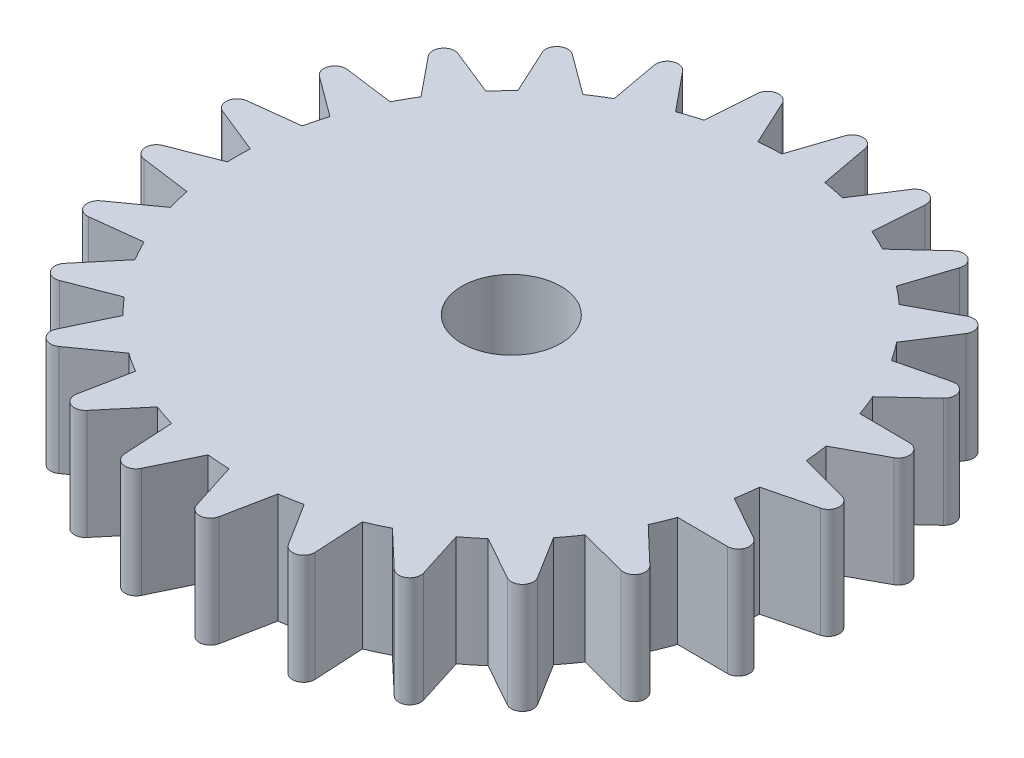
from build123d import *

# Parameters (mm, degrees)
BOSS_EXTRUDE1_DEPTH = 5
SKETCH6_R           = 2.25
CUT_EXTRUDE1_DEPTH  = 6


with BuildPart() as part:
    # Sketch1 → Boss-Extrude1 (new body)
    with BuildSketch(Plane(origin=(0, -74.1, 0), x_dir=(1, 0, 0), z_dir=(0, 1, 0))):
        with BuildLine():
            Line((-5.573417888, -7.249599077), (-3.909244984, -5.703911435))
            ThreePointArc((-3.909244984, -5.703911435), (-3.809726926, -5.099679562), (-4.369892407, -4.852263649))
            Line((-4.369892407, -4.852263649), (-6.574346511, -5.399076092))
            ThreePointArc((-6.574346511, -5.399076092), (-6.86485582, -4.975241994), (-7.172578897, -4.563735604))
            Line((-7.172578897, -4.563735604), (-5.94508593, -2.65274561))
            ThreePointArc((-5.94508593, -2.65274561), (-5.998960771, -2.042747658), (-6.603057459, -1.942412262))
            Line((-6.603057459, -1.942412262), (-8.602267858, -3.020271029))
            ThreePointArc((-8.602267858, -3.020271029), (-8.989053537, -2.681999186), (-9.389446406, -2.359948643))
            Line((-9.389446406, -2.359948643), (-8.675761274, -0.203730826))
            ThreePointArc((-8.675761274, -0.203730826), (-8.87964386, 0.37370479), (-9.489714138, 0.320655229))
            Line((-9.489714138, 0.320655229), (-11.158063091, -1.220524032))
            ThreePointArc((-11.158063091, -1.220524032), (-11.616821973, -0.989069307), (-12.084726477, -0.776710232))
            Line((-12.084726477, -0.776710232), (-11.92969264, 1.489252312))
            ThreePointArc((-11.92969264, 1.489252312), (-12.270772279, 1.997843189), (-12.848483188, 1.794741969))
            Line((-12.848483188, 1.794741969), (-14.081142194, -0.112919824))
            ThreePointArc((-14.081142194, -0.112919824), (-14.583048772, -0.00282537), (-15.089064749, 0.086498936))
            Line((-15.089064749, 0.086498936), (-15.502423555, 2.319827447))
            ThreePointArc((-15.502423555, 2.319827447), (-15.959268957, 2.72761695), (-16.468320796, 2.387225667))
            Line((-16.468320796, 2.387225667), (-17.187837357, 0.232946748))
            ThreePointArc((-17.187837357, 0.232946748), (-17.701354994, 0.214763292), (-18.213687601, 0.175440255))
            Line((-18.213687601, 0.175440255), (-19.169466196, 2.235806489))
            ThreePointArc((-19.169466196, 2.235806489), (-19.713372085, 2.517171704), (-20.121779254, 2.060878394))
            Line((-20.121779254, 2.060878394), (-20.282943498, -0.204656383))
            ThreePointArc((-20.282943498, -0.204656383), (-20.775805993, -0.349975216), (-21.262263487, -0.515474786))
            Line((-21.262263487, -0.515474786), (-22.700406786, 1.242468784))
            ThreePointArc((-22.700406786, 1.242468784), (-23.297197554, 1.379730498), (-23.57929833, 0.83620575))
            Line((-23.57929833, 0.83620575), (-23.171983715, -1.398233005))
            ThreePointArc((-23.171983715, -1.398233005), (-23.613222703, -1.661556297), (-24.043239171, -1.942833453))
            Line((-24.043239171, -1.942833453), (-25.873383342, -0.597770608))
            ThreePointArc((-25.873383342, -0.597770608), (-26.485560432, -0.613237052), (-26.623629384, -1.209841581))
            Line((-26.623629384, -1.209841581), (-25.673428985, -3.272786307))
            ThreePointArc((-25.673428985, -3.272786307), (-26.0353198, -3.637568488), (-26.381875725, -4.016949552))
            Line((-26.381875725, -4.016949552), (-28.489026078, -3.169282677))
            ThreePointArc((-28.489026078, -3.169282677), (-29.078124151, -3.336505465), (-29.063485901, -3.948702919))
            Line((-29.063485901, -3.948702919), (-27.630104303, -5.710531213))
            ThreePointArc((-27.630104303, -5.710531213), (-27.889908013, -6.153851676), (-28.131228013, -6.607498741))
            Line((-28.131228013, -6.607498741), (-30.382984542, -6.310489863))
            ThreePointArc((-30.382984542, -6.310489863), (-30.911988399, -6.618961773), (-30.745562721, -7.208285533))
            Line((-30.745562721, -7.208285533), (-28.919064562, -8.558295243))
            ThreePointArc((-28.919064562, -8.558295243), (-29.060456745, -9.052298535), (-29.181377796, -9.551707286))
            Line((-29.181377796, -9.551707286), (-31.436254358, -9.824018565))
            ThreePointArc((-31.436254358, -9.824018565), (-31.871924741, -10.254357173), (-31.564168772, -10.783777859))
            Line((-31.564168772, -10.783777859), (-29.459319649, -11.637142911))
            ThreePointArc((-29.459319649, -11.637142911), (-29.473416113, -12.150788987), (-29.466340301, -12.664579737))
            Line((-29.466340301, -12.664579737), (-31.582654708, -13.489100854))
            ThreePointArc((-31.582654708, -13.489100854), (-31.897616846, -14.014266401), (-31.467868026, -14.450518566))
            Line((-31.467868026, -14.450518566), (-29.21692335, -14.753618895))
            ThreePointArc((-29.21692335, -14.753618895), (-29.102838363, -15.254633483), (-28.968210287, -15.750522868))
            Line((-28.968210287, -15.750522868), (-30.812986722, -17.07544613))
            ThreePointArc((-30.812986722, -17.07544613), (-30.987450384, -17.662440534), (-30.462711412, -17.97811285))
            Line((-30.462711412, -17.97811285), (-28.207106316, -17.711903547))
            ThreePointArc((-28.207106316, -17.711903547), (-27.972008257, -18.168806058), (-27.718287094, -18.615635525))
            Line((-27.718287094, -18.615635525), (-29.175611469, -20.357711129))
            ThreePointArc((-29.175611469, -20.357711129), (-29.198614462, -20.969651374), (-28.611856617, -21.144908987))
            Line((-28.611856617, -21.144908987), (-26.493319064, -20.326116962))
            ThreePointArc((-26.493319064, -20.326116962), (-26.151980009, -20.710198531), (-25.795107994, -21.079892141))
            Line((-25.795107994, -21.079892141), (-26.773411257, -23.129659071))
            ThreePointArc((-26.773411257, -23.129659071), (-26.643508219, -23.728094699), (-26.031599654, -23.75192553))
            Line((-26.031599654, -23.75192553), (-24.183245151, -22.431998497))
            ThreePointArc((-24.183245151, -22.431998497), (-23.757112689, -22.719125866), (-23.319513401, -22.988454411))
            Line((-23.319513401, -22.988454411), (-23.757325162, -25.217118272))
            ThreePointArc((-23.757325162, -25.217118272), (-23.482678378, -25.764447372), (-22.88406756, -25.635354042))
            Line((-22.88406756, -25.635354042), (-21.422035016, -23.897227871))
            ThreePointArc((-21.422035016, -23.897227871), (-20.937884616, -24.069359772), (-20.44705403, -24.221400348))
            Line((-20.44705403, -24.221400348), (-20.316864965, -26.488925992))
            ThreePointArc((-20.316864965, -26.488925992), (-19.914731502, -26.950757865), (-19.367031349, -26.676851782))
            Line((-19.367031349, -26.676851782), (-18.383185648, -24.629739333))
            ThreePointArc((-18.383185648, -24.629739333), (-17.87143826, -24.676060085), (-17.358217065, -24.701259423))
            Line((-17.358217065, -24.701259423), (-16.668207433, -26.865169876))
            ThreePointArc((-16.668207433, -26.865169876), (-16.163854816, -27.212485926), (-15.701479344, -26.810977617))
            Line((-15.701479344, -26.810977617), (-15.257639128, -24.583506493))
            ThreePointArc((-15.257639128, -24.583506493), (-14.750449723, -24.501105593), (-14.247085495, -24.397880327))
            Line((-14.247085495, -24.397880327), (-13.040611138, -26.322209137))
            ThreePointArc((-13.040611138, -26.322209137), (-12.465729697, -26.533186219), (-12.117731656, -26.029303927))
            Line((-12.117731656, -26.029303927), (-12.241785039, -23.761434332))
            ThreePointArc((-12.241785039, -23.761434332), (-11.771022192, -23.555489332), (-11.309143157, -23.330325485))
            Line((-11.309143157, -23.330325485), (-9.662011296, -24.894159994))
            ThreePointArc((-9.662011296, -24.894159994), (-9.052722946, -24.955541642), (-8.840968333, -24.380946146))
            Line((-8.840968333, -24.380946146), (-9.525120585, -22.215176667))
            ThreePointArc((-9.525120585, -22.215176667), (-9.120364058, -21.898627848), (-8.728991773, -21.565673292))
            Line((-8.728991773, -21.565673292), (-6.744697761, -22.670752028))
            ThreePointArc((-6.744697761, -22.670752028), (-6.139286329, -22.578681408), (-6.077080467, -21.969476655))
            Line((-6.077080467, -21.969476655), (-7.278343785, -20.041890553))
            ThreePointArc((-7.278343785, -20.041890553), (-6.965025918, -19.634627842), (-6.668751745, -19.214803336))
            Line((-6.668751745, -19.214803336), (-4.471976071, -19.791690138))
            ThreePointArc((-4.471976071, -19.791690138), (-3.908481786, -19.551952385), (-3.999733295, -18.94641695))
            Line((-3.999733295, -18.94641695), (-5.642627888, -17.378131549))
            ThreePointArc((-5.642627888, -17.378131549), (-5.440435595, -16.905744761), (-5.257875529, -16.425429423))
            Line((-5.257875529, -16.425429423), (-2.986649689, -16.43787637))
            ThreePointArc((-2.986649689, -16.43787637), (-2.500478968, -16.065535089), (-2.739454182, -15.501716992))
            Line((-2.739454182, -15.501716992), (-4.72075094, -14.391273432))
            ThreePointArc((-4.72075094, -14.391273432), (-4.642388707, -13.883444364), (-4.585013668, -13.372818174))
            Line((-4.585013668, -13.372818174), (-2.382047135, -12.820043179))
            ThreePointArc((-2.382047135, -12.820043179), (-2.003747871, -12.338493942), (-2.375431099, -11.851819947))
            Line((-2.375431099, -11.851819947), (-4.570637859, -11.26899148))
            ThreePointArc((-4.570637859, -11.26899148), (-4.621029474, -10.757628901), (-4.692444547, -10.24877638))
            Line((-4.692444547, -10.24877638), (-2.696157809, -9.16551233))
            ThreePointArc((-2.696157809, -9.16551233), (-2.449499938, -8.605012646), (-2.930536955, -8.226062269))
            Line((-2.930536955, -8.226062269), (-5.201720804, -8.207470152))
            ThreePointArc((-5.201720804, -8.207470152), (-5.377699975, -7.724704854), (-5.573417888, -7.249599077))
        make_face()
    extrude(amount=-BOSS_EXTRUDE1_DEPTH)

    # Sketch6 → Cut-Extrude1 (cut, through all)
    with BuildSketch(Plane(origin=(0, -74.1, 0), x_dir=(1, 0, 0), z_dir=(0, 1, 0))):
        with Locations((-17.003397692, -12.235998762)):
            Circle(SKETCH6_R)
    extrude(amount=-CUT_EXTRUDE1_DEPTH, mode=Mode.SUBTRACT)


solid = part.part
